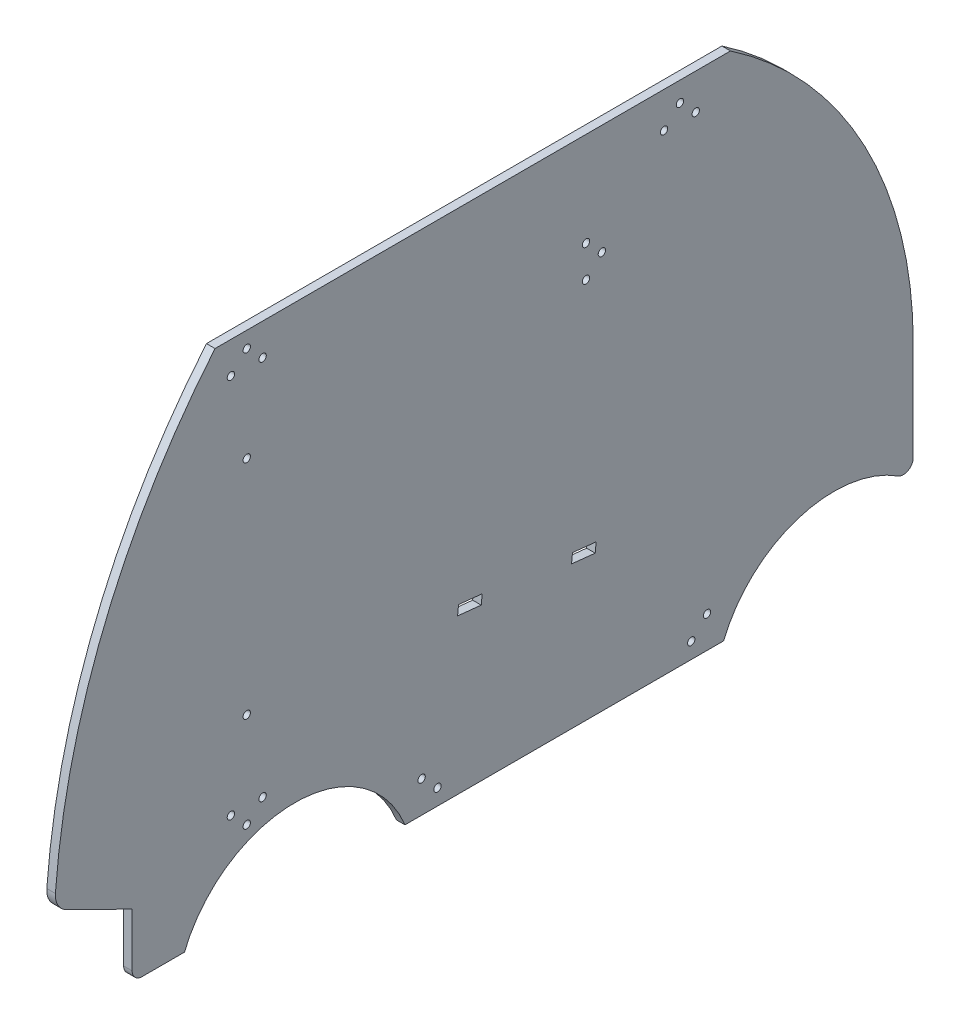
from build123d import *

# Parameters (mm, degrees)
SKETCH1_R           = 1.85
BOSS_EXTRUDE1_DEPTH = 4.318


with BuildPart() as part:
    # Sketch1 → Boss-Extrude1 (new body)
    with BuildSketch(Plane(origin=(0, 0, 0), x_dir=(0, 0, -1), z_dir=(1, 0, 0))):
        with BuildLine():
            Line((136.240741284, 32.272255751), (136.240741284, 82.154119676))
            ThreePointArc((136.240741284, 82.154119676), (111.765249408, 180.544448903), (44.044009042, 256))
            Line((44.044009042, 256), (-215.955990958, 256))
            ThreePointArc((-215.955990958, 256), (-271.683097829, 163.39777941), (-296.50139881, 58.208741794))
            ThreePointArc((-296.50139881, 58.208741794), (-295.198004633, 52.399053051), (-290.863193916, 48.3172966))
            Line((-290.863193916, 48.3172966), (-257.759258716, 32))
            Line((-257.759258716, 32), (-257.759258716, 5))
            ThreePointArc((-257.759258716, 5), (-256.294792622, 1.464466094), (-252.759258716, 0))
            Line((-252.759258716, 0), (-231.380747369, 0))
            ThreePointArc((-231.380747369, 0), (-175.759258716, 37.5), (-120.137770063, 0))
            Line((-120.137770063, 0), (40.619252631, 0))
            ThreePointArc((40.619252631, 0), (78.000395352, 34.660211514), (128.548433592, 28.059005308))
            ThreePointArc((128.548433592, 28.059005308), (133.642663591, 27.886965654), (136.240741284, 32.272255751))
        make_face()
        with Locations((-207.955990958, 48)):
            Circle(SKETCH1_R, mode=Mode.SUBTRACT)
        with Locations((-191.955990958, 48)):
            Circle(SKETCH1_R, mode=Mode.SUBTRACT)
        with Locations((-199.955990958, 40)):
            Circle(SKETCH1_R, mode=Mode.SUBTRACT)
        with Locations((-199.955990958, 200)):
            Circle(SKETCH1_R, mode=Mode.SUBTRACT)
        with Locations((-191.955990958, 240)):
            Circle(SKETCH1_R, mode=Mode.SUBTRACT)
        with Locations((-207.955990958, 240)):
            Circle(SKETCH1_R, mode=Mode.SUBTRACT)
        with Locations((-199.955990958, 248)):
            Circle(SKETCH1_R, mode=Mode.SUBTRACT)
        with Locations((-199.955990958, 88)):
            Circle(SKETCH1_R, mode=Mode.SUBTRACT)
        with Locations((-111.759258716, 16)):
            Circle(SKETCH1_R, mode=Mode.SUBTRACT)
        with Locations((32.240741284, 16)):
            Circle(SKETCH1_R, mode=Mode.SUBTRACT)
        with Locations((24.240741284, 8)):
            Circle(SKETCH1_R, mode=Mode.SUBTRACT)
        with Locations((-103.759258716, 8)):
            Circle(SKETCH1_R, mode=Mode.SUBTRACT)
        with Locations((-28.820215612, 192.5)):
            Circle(SKETCH1_R, mode=Mode.SUBTRACT)
        with Locations((-20.820215612, 200.5)):
            Circle(SKETCH1_R, mode=Mode.SUBTRACT)
        with Locations((-28.820215612, 208.5)):
            Circle(SKETCH1_R, mode=Mode.SUBTRACT)
        with Locations((26.544009042, 238)):
            Circle(SKETCH1_R, mode=Mode.SUBTRACT)
        with Locations((10.544009042, 238)):
            Circle(SKETCH1_R, mode=Mode.SUBTRACT)
        with Locations((18.544009042, 246)):
            Circle(SKETCH1_R, mode=Mode.SUBTRACT)
        Polygon((-93.121069237, 82.721950219), (-81.186806492, 81.46760866), (-81.680426507, 76.771127937), (-93.614689252, 78.025469496), align=None, mode=Mode.SUBTRACT)
        Polygon((-35.639064197, 76.680348038), (-23.704801453, 75.426006479), (-24.198421467, 70.729525756), (-36.132684212, 71.983867315), align=None, mode=Mode.SUBTRACT)
    extrude(amount=BOSS_EXTRUDE1_DEPTH)


solid = part.part
